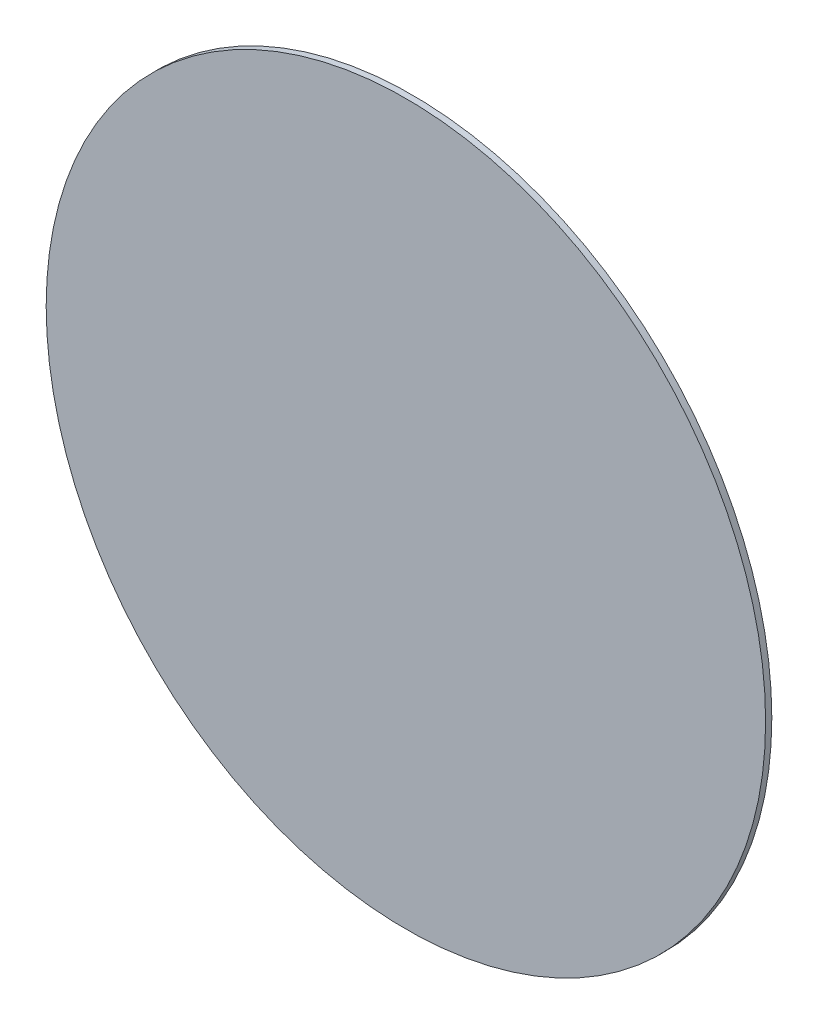
from build123d import *

# Parameters (mm, degrees)
SKETCH2_R           = 200
BOSS_EXTRUDE1_DEPTH = 1.725


with BuildPart() as part:
    # Sketch2 → Boss-Extrude1 (new body, symmetric)
    with BuildSketch(Plane.XY):
        Circle(SKETCH2_R)
    extrude(amount=BOSS_EXTRUDE1_DEPTH, both=True)


solid = part.part
